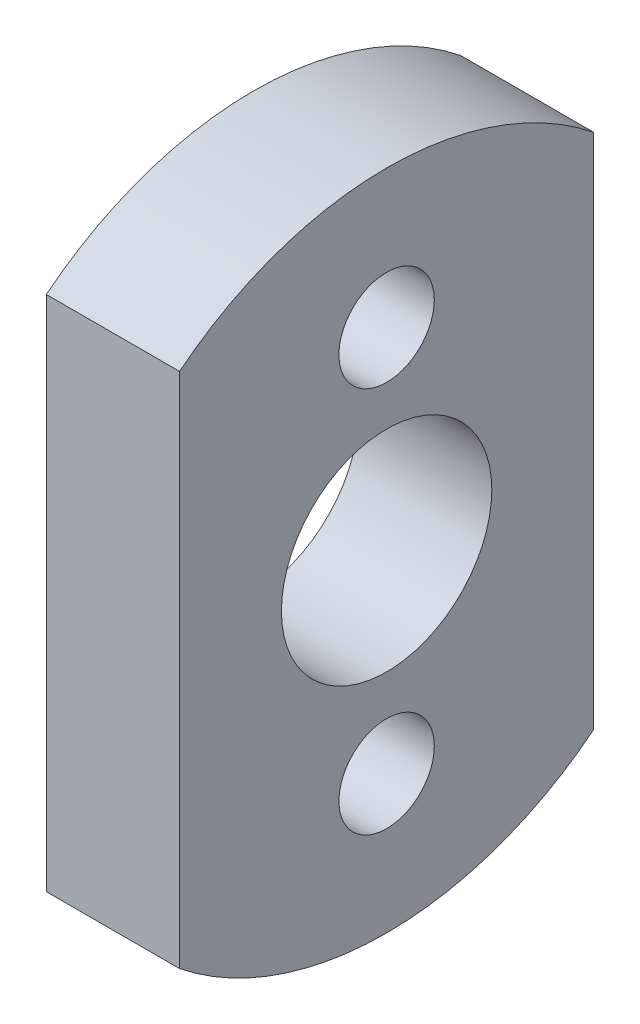
from build123d import *

# Parameters (mm, degrees)
SKETCH1_R           = 1.7272
SKETCH1_R_2         = 3.81
BOSS_EXTRUDE1_DEPTH = 4.826


with BuildPart() as part:
    # Sketch1 → Boss-Extrude1 (new body)
    with BuildSketch(Plane(origin=(0, 0, 0), x_dir=(0, 0, -1), z_dir=(1, 0, 0))):
        with BuildLine():
            Line((-7.5, 9.367496998), (-7.5, -9.367496998))
            ThreePointArc((-7.5, -9.367496998), (0, -12), (7.5, -9.367496998))
            Line((7.5, -9.367496998), (7.5, 9.367496998))
            ThreePointArc((7.5, 9.367496998), (0, 12), (-7.5, 9.367496998))
        make_face()
        with Locations((0, 7)):
            Circle(SKETCH1_R, mode=Mode.SUBTRACT)
        with Locations((0, -7)):
            Circle(SKETCH1_R, mode=Mode.SUBTRACT)
        Circle(SKETCH1_R_2, mode=Mode.SUBTRACT)
    extrude(amount=BOSS_EXTRUDE1_DEPTH)


solid = part.part
